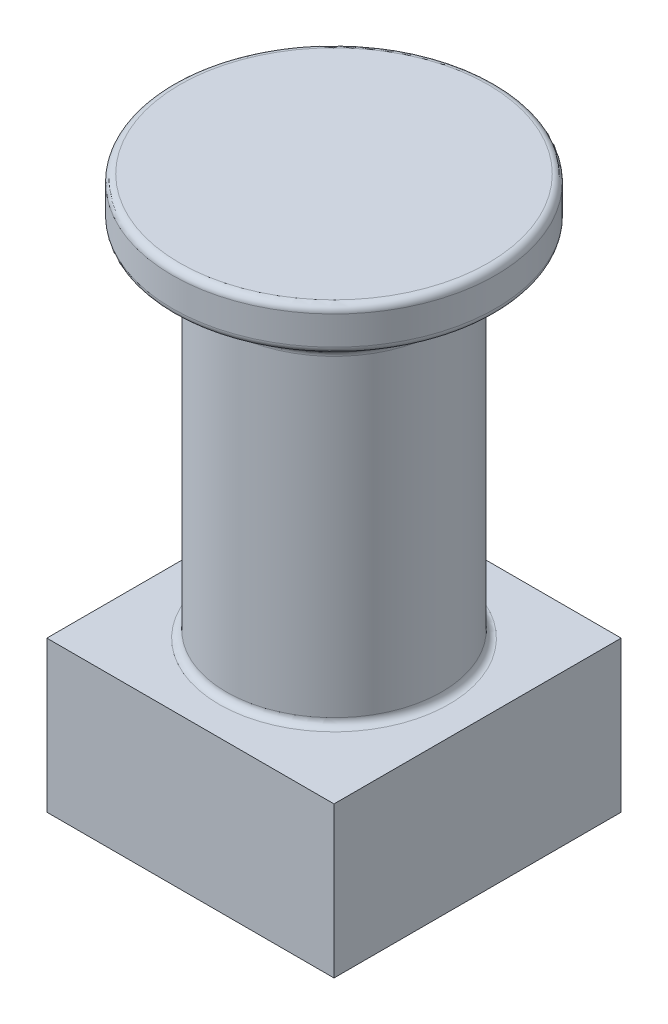
from build123d import *

# Parameters (mm, degrees)
SKETCH_2_W      = 40
SKETCH_2_H      = 40
EXTRUDE_1_DEPTH = 21
SKETCH_3_R      = 15
EXTRUDE_2_DEPTH = 50
SKETCH_4_R      = 22.5
EXTRUDE_3_DEPTH = 6
CHAMFER_1_SIZE  = 5
FILLET_1_R      = 1


with BuildPart() as part:
    # 草图2 → 凸台-拉伸1 (new body)
    with BuildSketch(Plane(origin=(0, 0, 0), x_dir=(1, 0, 0), z_dir=(0, 1, 0))):
        Rectangle(SKETCH_2_W, SKETCH_2_H)
    extrude(amount=EXTRUDE_1_DEPTH)

    # 草图3 → 凸台-拉伸2 (add)
    with BuildSketch(Plane(origin=(0, 21, 0), x_dir=(1, 0, 0), z_dir=(0, 1, 0))):
        Circle(SKETCH_3_R)
    extrude(amount=EXTRUDE_2_DEPTH)

    # 草图4 → 凸台-拉伸3 (add)
    with BuildSketch(Plane(origin=(0, 71, 0), x_dir=(1, 0, 0), z_dir=(0, 1, 0))):
        Circle(SKETCH_4_R)
    extrude(amount=EXTRUDE_3_DEPTH)

    # 倒角1
    chamfer_1_edges = [part.edges().sort_by_distance(p)[0] for p in [
        (-15, 71, 0),
    ]]
    chamfer(chamfer_1_edges, length=CHAMFER_1_SIZE)

    # 圆角1
    fillet_1_edges = [part.edges().sort_by_distance(p)[0] for p in [
        (-15, 21, 0),
        (-22.5, 71, 0),
        (-22.5, 77, 0),
        (-20, 71, 0),
        (-15, 66, 0),
    ]]
    fillet(fillet_1_edges, radius=FILLET_1_R)


solid = part.part
